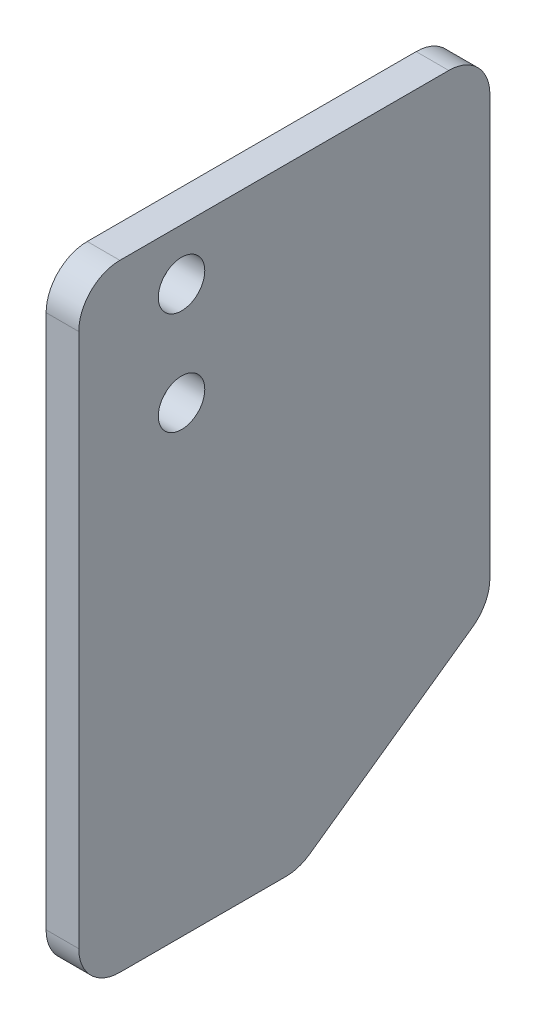
from build123d import *

# Parameters (mm, degrees)
SKETCH_1_R      = 1.1303
EXTRUDE_1_DEPTH = 1.588


with BuildPart() as part:
    # 草图1 → 凸台-拉伸1 (new body)
    with BuildSketch(Plane(origin=(-0.79375, 0, 0), x_dir=(0, -1, 0), z_dir=(-1, 0, 0))):
        with BuildLine():
            Line((40.795, -5.078289511), (40.795, 3))
            ThreePointArc((40.795, 3), (40.209213562, 4.414213562), (38.795, 5))
            Line((38.795, 5), (12.795, 5))
            ThreePointArc((12.795, 5), (11.380786438, 4.414213562), (10.795, 3))
            Line((10.795, 3), (10.795, -13))
            ThreePointArc((10.795, -13), (11.380786438, -14.414213562), (12.795, -15))
            Line((12.795, -15), (33.193504795, -15))
            ThreePointArc((33.193504795, -15), (34.112906481, -14.776147668), (34.826497957, -14.154700538))
            Line((34.826497957, -14.154700538), (40.427993162, -6.232990049))
            ThreePointArc((40.427993162, -6.232990049), (40.701041228, -5.684100404), (40.795, -5.078289511))
        make_face()
        with Locations((18.295, 0)):
            Circle(SKETCH_1_R, mode=Mode.SUBTRACT)
        with Locations((13.295, 0)):
            Circle(SKETCH_1_R, mode=Mode.SUBTRACT)
    extrude(amount=-EXTRUDE_1_DEPTH)


solid = part.part
